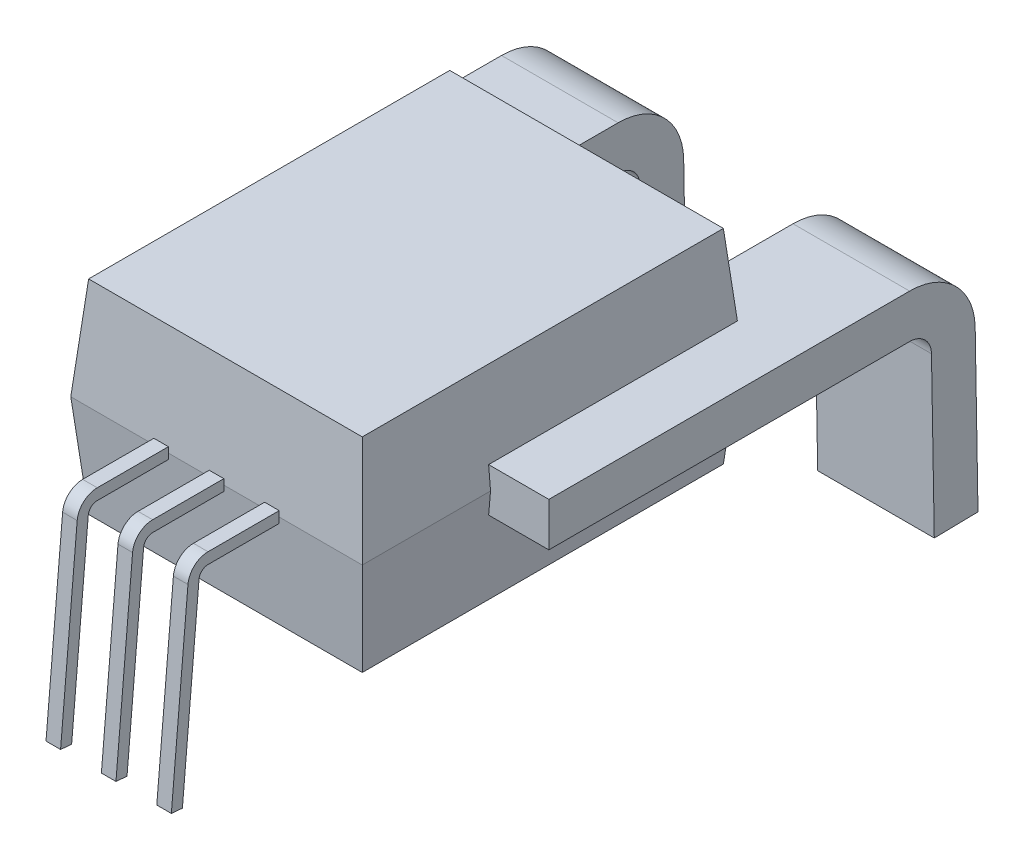
from build123d import *

# Parameters (mm, degrees)
SKETCH1_W                = 10
SKETCH1_H                = 13
EXTRUDE1_DEPTH           = 3.5
EXTRUDE1_TAPER           = 5
EXTRUDE1_OTHER_WAY_DEPTH = 3.5
EXTRUDE1_OTHER_WAY_TAPER = 5
SKETCH3_W                = 0.5
SKETCH3_H                = 0.381
SKETCH5_W                = 4
SKETCH5_H                = 1.5


with BuildPart() as part:
    # Sketch1 → Extrude1 (new body)
    with BuildSketch(Plane(origin=(0, 0, 0), x_dir=(1, 0, 0), z_dir=(0, 1, 0))):
        Rectangle(SKETCH1_W, SKETCH1_H)
    extrude(amount=EXTRUDE1_DEPTH, taper=EXTRUDE1_TAPER)

    # Sketch1 → Extrude1 other way (add)
    with BuildSketch(Plane(origin=(0, 0, 0), x_dir=(1, 0, 0), z_dir=(0, 1, 0))):
        Rectangle(SKETCH1_W, SKETCH1_H)
    extrude(amount=-EXTRUDE1_OTHER_WAY_DEPTH, taper=EXTRUDE1_OTHER_WAY_TAPER)

    # Sweep2: sweep along a path in Sketch4
    with BuildLine(Plane(origin=(5, 0, 0), x_dir=(0, 0, -1), z_dir=(1, 0, 0))) as sweep2_path:
        Line((-2.1, 0), (10.275954105, 0))
        ThreePointArc((10.275954105, 0), (11.327318002, -0.430124326), (11.775725648, -1.47382139))
        Line((11.775725648, -1.47382139), (11.87212638, -6.996615616))
    # Sketch5 → Sweep2 (sweep)
    with BuildSketch(Plane.XY.offset(2.1)):
        with Locations((5, 0)):
            Rectangle(SKETCH5_W, SKETCH5_H)
    sweep2 = sweep(path=sweep2_path.line)

    # Mirror1: Sweep2 across plane
    add(sweep2.mirror(Plane(origin=(0, 0, 0), x_dir=(0, 0, 1), z_dir=(1, 0, 0))))


with BuildPart() as body_2:
    # Sweep1: sweep along a path in Sketch2
    with BuildLine(Plane(origin=(0, 0, 0), x_dir=(0, 0, -1), z_dir=(1, 0, 0))) as sweep1_path:
        Line((-6.5, 0), (-8.941834413, 0))
        ThreePointArc((-8.941834413, 0), (-9.279629517, -0.131361332), (-9.439931762, -0.456422129))
        Line((-9.439931762, -0.456422129), (-10.010090199, -6.973362887))
    # Sketch3 → Sweep1 (sweep)
    with BuildSketch(Plane.XY.offset(6.5)):
        with Locations((1.9, 0)):
            Rectangle(SKETCH3_W, SKETCH3_H)
        Rectangle(SKETCH3_W, SKETCH3_H)
        with Locations((-1.9, 0)):
            Rectangle(SKETCH3_W, SKETCH3_H)
    sweep(path=sweep1_path.line)


solid = Compound([part.part, body_2.part])
